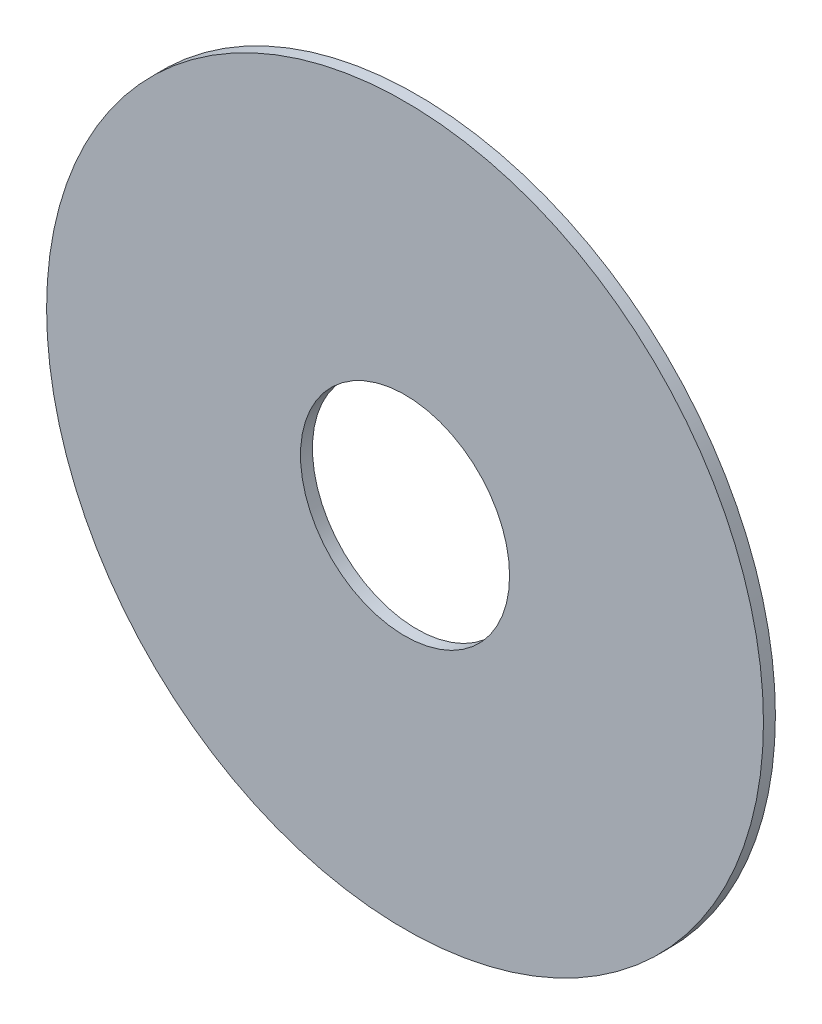
from build123d import *

# Parameters (mm, degrees)
SKETCH1_R           = 15.24
BOSS_EXTRUDE1_DEPTH = 0.508
SKETCH2_R           = 4.445
CUT_EXTRUDE1_DEPTH  = 1.508


with BuildPart() as part:
    # Sketch1 → Boss-Extrude1 (new body)
    with BuildSketch(Plane.XY):
        Circle(SKETCH1_R)
    extrude(amount=BOSS_EXTRUDE1_DEPTH)

    # Sketch2 → Cut-Extrude1 (cut, through all)
    with BuildSketch(Plane.XY.offset(0.508)):
        Circle(SKETCH2_R)
    extrude(amount=-CUT_EXTRUDE1_DEPTH, mode=Mode.SUBTRACT)


solid = part.part
